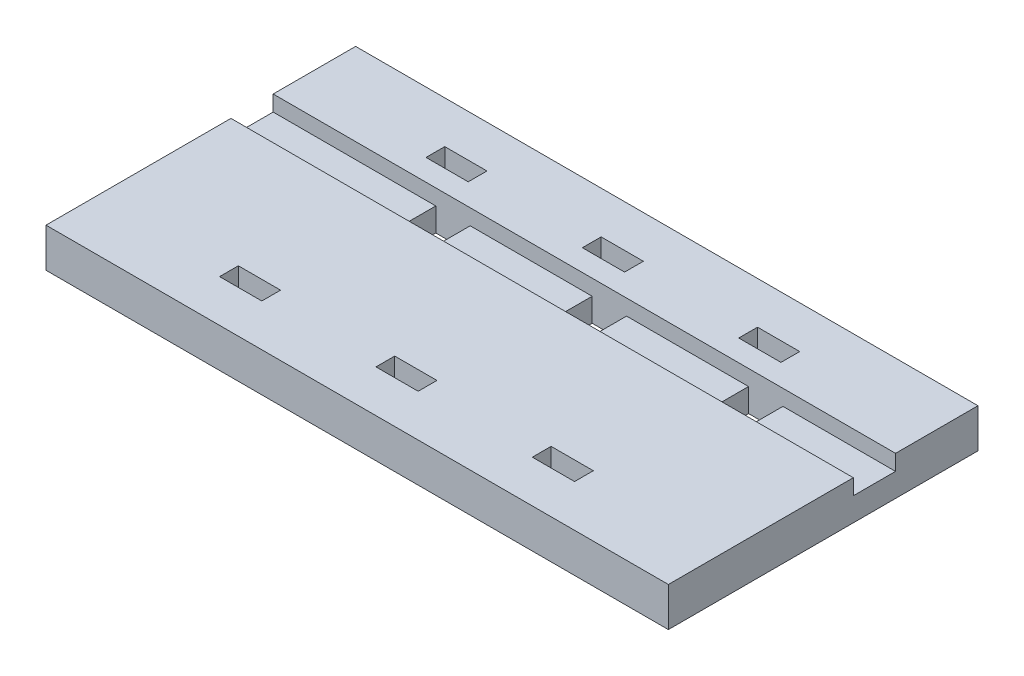
from build123d import *

# Parameters (mm, degrees)
SKETCH1_W                     = 101.092
SKETCH1_H                     = 50.292
BOSS_EXTRUDE1_DEPTH           = 6.35
SKETCH2_W                     = 5.588
SKETCH2_H                     = 6.858
WIRE_HOLE_DEPTH               = 7.35
SKETCH3_W                     = 6.858
SKETCH3_H                     = 3.048
CUT_EXTRUDE2_DEPTH            = 3.81
LPATTERN1_COUNT               = 2
LPATTERN1_PITCH               = 25.4
LPATTERN1_COPY_1_SKETCH_W     = 6.858
LPATTERN1_COPY_1_SKETCH_H     = 3.048
LPATTERN1_COPY_1_DEPTH        = 3.81
LPATTERN1_COL_COUNT           = 2
LPATTERN1_COL_PITCH           = 25.4
LPATTERN1_COL_COPY_1_SKETCH_W = 6.858
LPATTERN1_COL_COPY_1_SKETCH_H = 3.048
LPATTERN1_COL_COPY_1_DEPTH    = 3.81
SKETCH4_W                     = 101.092
SKETCH4_H                     = 6.858
CUT_EXTRUDE3_DEPTH            = 2.54


with BuildPart() as part:
    # Sketch1 → Boss-Extrude1 (new body)
    with BuildSketch(Plane(origin=(0, 0, 0), x_dir=(1, 0, 0), z_dir=(0, 1, 0))):
        Rectangle(SKETCH1_W, SKETCH1_H)
    extrude(amount=BOSS_EXTRUDE1_DEPTH)

    # Sketch2 → Wire Hole (cut, through all)
    with BuildSketch(Plane(origin=(0, 6.35, 0), x_dir=(1, 0, 0), z_dir=(0, 1, 0))):
        with Locations((4.064, 8.322545685)):
            Rectangle(SKETCH2_W, SKETCH2_H)
    wire_hole = extrude(amount=-WIRE_HOLE_DEPTH, mode=Mode.SUBTRACT)

    # Sketch3 → Cut-Extrude2 (cut)
    with BuildSketch(Plane(origin=(0, 6.35, 0), x_dir=(1, 0, 0), z_dir=(0, 1, 0))):
        with Locations((-0.381, 16.764)):
            Rectangle(SKETCH3_W, SKETCH3_H)
    cut_extrude2 = extrude(amount=-CUT_EXTRUDE2_DEPTH, mode=Mode.SUBTRACT)

    # Mirror1: Cut-Extrude2 across plane
    add(cut_extrude2.mirror(Plane.XY), mode=Mode.SUBTRACT)

    # LPattern1: Wire Hole, Cut-Extrude2 ×2
    with Locations(*[(-i * LPATTERN1_PITCH, 0, 0) for i in range(1, LPATTERN1_COUNT)]):
        add(wire_hole, mode=Mode.SUBTRACT)
        add(cut_extrude2, mode=Mode.SUBTRACT)

    # LPattern1 copy 1 sketch → LPattern1 copy 1 (cut)
    with BuildSketch(Plane(origin=(-25.4, 6.35, 0), x_dir=(1, 0, 0), z_dir=(0, 1, 0))):
        with Locations((-0.381, -16.764)):
            Rectangle(LPATTERN1_COPY_1_SKETCH_W, LPATTERN1_COPY_1_SKETCH_H)
    extrude(amount=-LPATTERN1_COPY_1_DEPTH, mode=Mode.SUBTRACT)

    # LPattern1 col: Wire Hole, Cut-Extrude2 ×2
    with Locations(*[(i * LPATTERN1_COL_PITCH, 0, 0) for i in range(1, LPATTERN1_COL_COUNT)]):
        add(wire_hole, mode=Mode.SUBTRACT)
        add(cut_extrude2, mode=Mode.SUBTRACT)

    # LPattern1 col copy 1 sketch → LPattern1 col copy 1 (cut)
    with BuildSketch(Plane(origin=(25.4, 6.35, 0), x_dir=(1, 0, 0), z_dir=(0, 1, 0))):
        with Locations((-0.381, -16.764)):
            Rectangle(LPATTERN1_COL_COPY_1_SKETCH_W, LPATTERN1_COL_COPY_1_SKETCH_H)
    extrude(amount=-LPATTERN1_COL_COPY_1_DEPTH, mode=Mode.SUBTRACT)

    # Sketch4 → Cut-Extrude3 (cut)
    with BuildSketch(Plane(origin=(0, 6.35, 0), x_dir=(1, 0, 0), z_dir=(0, 1, 0))):
        with Locations((0, 8.322545685)):
            Rectangle(SKETCH4_W, SKETCH4_H)
    extrude(amount=-CUT_EXTRUDE3_DEPTH, mode=Mode.SUBTRACT)


solid = part.part
